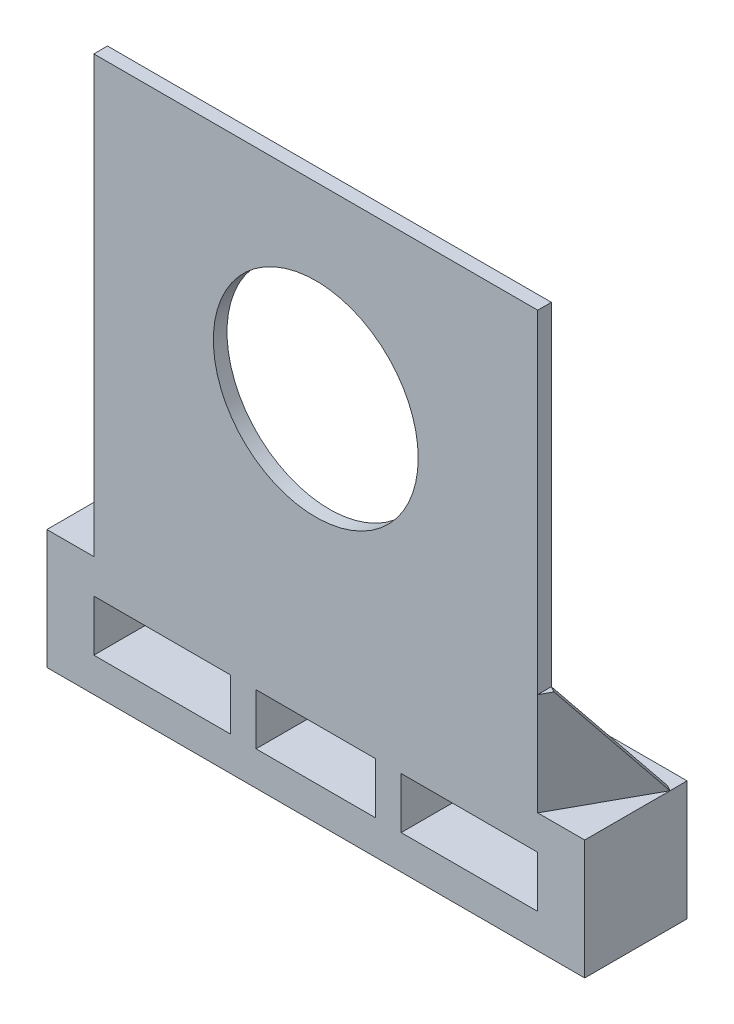
from build123d import *

# Parameters (mm, degrees)
SKETCH1_W           = 260
SKETCH1_H           = 255
SKETCH1_R           = 60
BOSS_EXTRUDE1_DEPTH = 8
SKETCH2_W           = 315
SKETCH2_H           = 70
SKETCH2_W_2         = 80
SKETCH2_H_2         = 30
SKETCH2_W_3         = 70
BOSS_EXTRUDE2_DEPTH = 60
BOSS_EXTRUDE3_DEPTH = 60
CUT_EXTRUDE1_REACH  = 282.827
CUT_EXTRUDE2_REACH  = 282.827


with BuildPart() as part:
    # Sketch1 → Boss-Extrude1 (new body)
    with BuildSketch(Plane.XY):
        with Locations((130, 127.5)):
            Rectangle(SKETCH1_W, SKETCH1_H)
        with Locations((130, 145)):
            Circle(SKETCH1_R, mode=Mode.SUBTRACT)
    extrude(amount=BOSS_EXTRUDE1_DEPTH)

    # Sketch2 → Boss-Extrude2 (add)
    with BuildSketch(Plane.XY.offset(8)):
        with Locations((130, -35)):
            Rectangle(SKETCH2_W, SKETCH2_H)
        with Locations((40, -35)):
            Rectangle(SKETCH2_W_2, SKETCH2_H_2, mode=Mode.SUBTRACT)
        with Locations((220, -35)):
            Rectangle(SKETCH2_W_2, SKETCH2_H_2, mode=Mode.SUBTRACT)
        with Locations((130, -35)):
            Rectangle(SKETCH2_W_3, SKETCH2_H_2, mode=Mode.SUBTRACT)
    extrude(amount=-BOSS_EXTRUDE2_DEPTH)

    # Sketch3 → Boss-Extrude3 (add)
    with BuildSketch(Plane(origin=(0, 0, 0), x_dir=(1, 0, 0), z_dir=(0, 1, 0))):
        Polygon((260, -8), (287.5, 42), (284.121880998, 43.857965451), (260, 0), align=None)
        Polygon((0, -8), (-27.5, 42), (-24.121880998, 43.857965451), (0, 0), align=None)
    extrude(amount=BOSS_EXTRUDE3_DEPTH)

    # Sketch4 → Cut-Extrude1 (cut, up to next)
    with BuildSketch(Plane(origin=(202.994241843, 0, 111.646833013), x_dir=(0.48191875, 0, -0.876215909), z_dir=(0.876215909, 0, 0.48191875)), mode=Mode.PRIVATE) as cut_extrude1_sk1:
        Polygon((175.352708724, 0), (125.298874941, 60), (175.352708724, 60), align=None)
    cut_extrude1_tool1 = extrude(cut_extrude1_sk1.sketch, amount=-CUT_EXTRUDE1_REACH, mode=Mode.PRIVATE) & part.part
    add(cut_extrude1_tool1.solids().sort_by_distance((279.459373, 40, -27.380678))[0], mode=Mode.SUBTRACT)

    # Sketch5 → Cut-Extrude2 (cut, up to next)
    with BuildSketch(Plane(origin=(-3.378119002, 0, 1.857965451), x_dir=(0.48191875, 0, 0.876215909), z_dir=(-0.876215909, 0, 0.48191875)), mode=Mode.PRIVATE) as cut_extrude2_sk1:
        Polygon((-50.053833783, 0), (0, 60), (-50.053833783, 60), align=None)
    cut_extrude2_tool1 = extrude(cut_extrude2_sk1.sketch, amount=-CUT_EXTRUDE2_REACH, mode=Mode.PRIVATE) & part.part
    add(cut_extrude2_tool1.solids().sort_by_distance((-19.459373, 40, -27.380678))[0], mode=Mode.SUBTRACT)


solid = part.part
